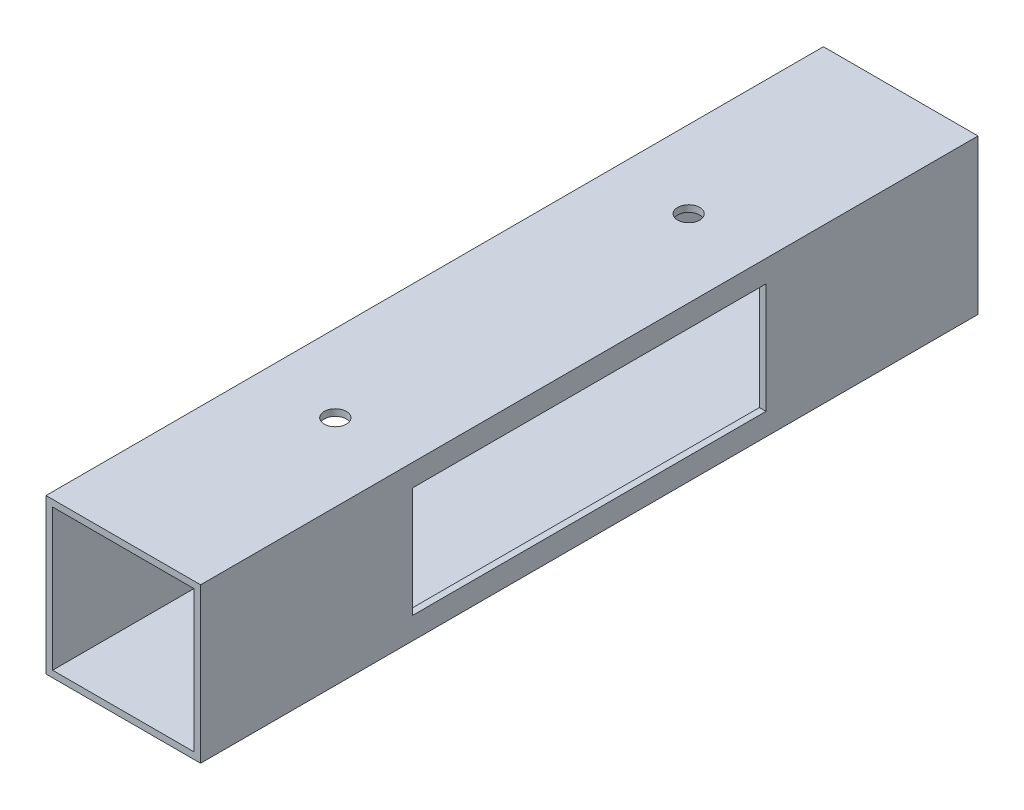
from build123d import *

# Parameters (mm, degrees)
MOTORBLOCKSKETCH_W         = 35
MOTORBLOCKSKETCH_H         = 35
MOTORBLOCKSKETCH_W_2       = 32
MOTORBLOCKSKETCH_H_2       = 32
BOSS_EXTRU_1_DEPTH         = 88
ESQUISSE3_W                = 80
ESQUISSE3_H                = 25
ENL_V_MAT_EXTRU_1_DEPTH    = 36
DRILLLEFTMOTORFIXSKETCH_R  = 2.5
ENL_V_MAT_EXTRU_2_DEPTH    = 5
DRILLRIGHTMOTORFIXSKETCH_R = 2.5
ENL_V_MAT_EXTRU_3_DEPTH    = 5


with BuildPart() as part:
    # MotorBlockSketch → Boss.-Extru.1 (new body, symmetric)
    with BuildSketch(Plane.XY):
        Rectangle(MOTORBLOCKSKETCH_W, MOTORBLOCKSKETCH_H)
        Rectangle(MOTORBLOCKSKETCH_W_2, MOTORBLOCKSKETCH_H_2, mode=Mode.SUBTRACT)
    extrude(amount=BOSS_EXTRU_1_DEPTH, both=True)

    # Esquisse3 → Enlèv. mat.-Extru.1 (cut, through all)
    with BuildSketch(Plane(origin=(17.5, 0, 0), x_dir=(0, 0, -1), z_dir=(1, 0, 0))):
        Rectangle(ESQUISSE3_W, ESQUISSE3_H)
    extrude(amount=-ENL_V_MAT_EXTRU_1_DEPTH, mode=Mode.SUBTRACT)

    # DrillLeftMotorFixSketch → Enlèv. mat.-Extru.2 (cut)
    with BuildSketch(Plane(origin=(0, 17.5, 0), x_dir=(1, 0, 0), z_dir=(0, 1, 0))):
        with Locations((0, 40)):
            Circle(DRILLLEFTMOTORFIXSKETCH_R)
    extrude(amount=-ENL_V_MAT_EXTRU_2_DEPTH, mode=Mode.SUBTRACT)

    # DrillRightMotorFixSketch → Enlèv. mat.-Extru.3 (cut)
    with BuildSketch(Plane(origin=(0, 17.5, 0), x_dir=(1, 0, 0), z_dir=(0, 1, 0))):
        with Locations((0, -40)):
            Circle(DRILLRIGHTMOTORFIXSKETCH_R)
    extrude(amount=-ENL_V_MAT_EXTRU_3_DEPTH, mode=Mode.SUBTRACT)


solid = part.part
